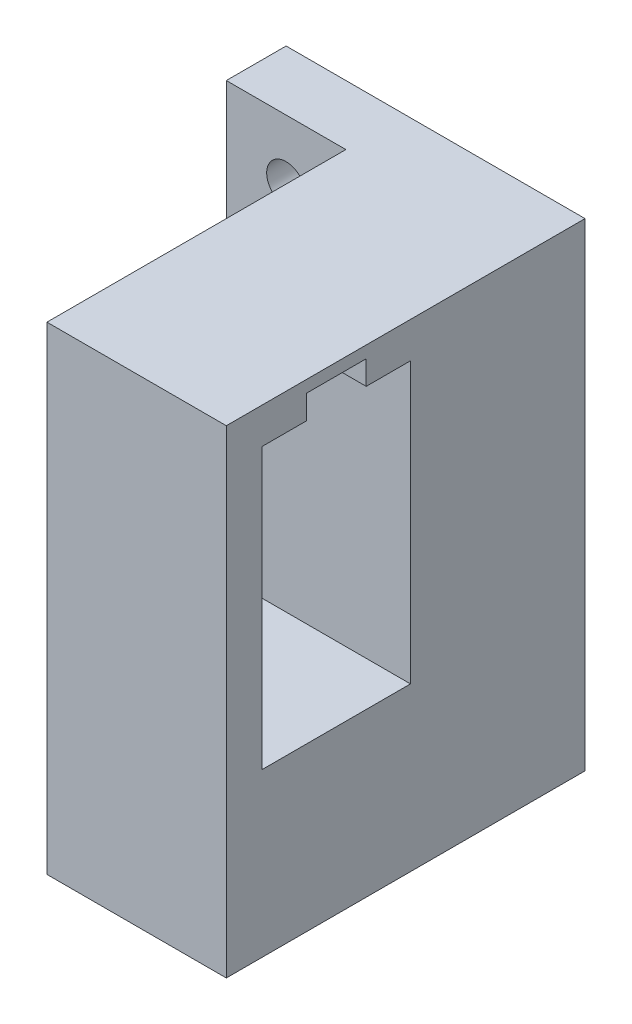
from build123d import *

# Parameters (mm, degrees)
ESQUISSE1_W             = 25
ESQUISSE1_H             = 40
BOSS_EXTRU_1_DEPTH      = 5
ESQUISSE2_R             = 1.625
ENL_V_MAT_EXTRU_1_DEPTH = 6
ESQUISSE3_W             = 15
ESQUISSE3_H             = 40
BOSS_EXTRU_2_DEPTH      = 25
ESQUISSE4_W             = 12.4
ESQUISSE4_H             = 23.4
ENL_V_MAT_EXTRU_2_DEPTH = 14
ESQUISSE5_W             = 5
ESQUISSE5_H             = 4
ENL_V_MAT_EXTRU_3_DEPTH = 26


with BuildPart() as part:
    # Esquisse1 → Boss.-Extru.1 (new body)
    with BuildSketch(Plane.XY):
        with Locations((12.5, -20)):
            Rectangle(ESQUISSE1_W, ESQUISSE1_H)
    extrude(amount=BOSS_EXTRU_1_DEPTH)

    # Esquisse2 → Enlèv. mat.-Extru.1 (cut, through all)
    with BuildSketch(Plane.XY.offset(5)):
        with Locations((5, -5)):
            Circle(ESQUISSE2_R)
        with Locations((5, -35)):
            Circle(ESQUISSE2_R)
    extrude(amount=-ENL_V_MAT_EXTRU_1_DEPTH, mode=Mode.SUBTRACT)

    # Esquisse3 → Boss.-Extru.2 (add)
    with BuildSketch(Plane.XY.offset(5)):
        with Locations((17.5, -20)):
            Rectangle(ESQUISSE3_W, ESQUISSE3_H)
    extrude(amount=BOSS_EXTRU_2_DEPTH)

    # Esquisse4 → Enlèv. mat.-Extru.2 (cut)
    with BuildSketch(Plane(origin=(25, 0, 0), x_dir=(0, 0, -1), z_dir=(1, 0, 0))):
        with Locations((-20.8, -14.7)):
            Rectangle(ESQUISSE4_W, ESQUISSE4_H)
    extrude(amount=-ENL_V_MAT_EXTRU_2_DEPTH, mode=Mode.SUBTRACT)

    # Esquisse5 → Enlèv. mat.-Extru.3 (cut, through all)
    with BuildSketch(Plane(origin=(25, 0, 0), x_dir=(0, 0, -1), z_dir=(1, 0, 0))):
        with Locations((-20.8, -3)):
            Rectangle(ESQUISSE5_W, ESQUISSE5_H)
    extrude(amount=-ENL_V_MAT_EXTRU_3_DEPTH, mode=Mode.SUBTRACT)


solid = part.part
